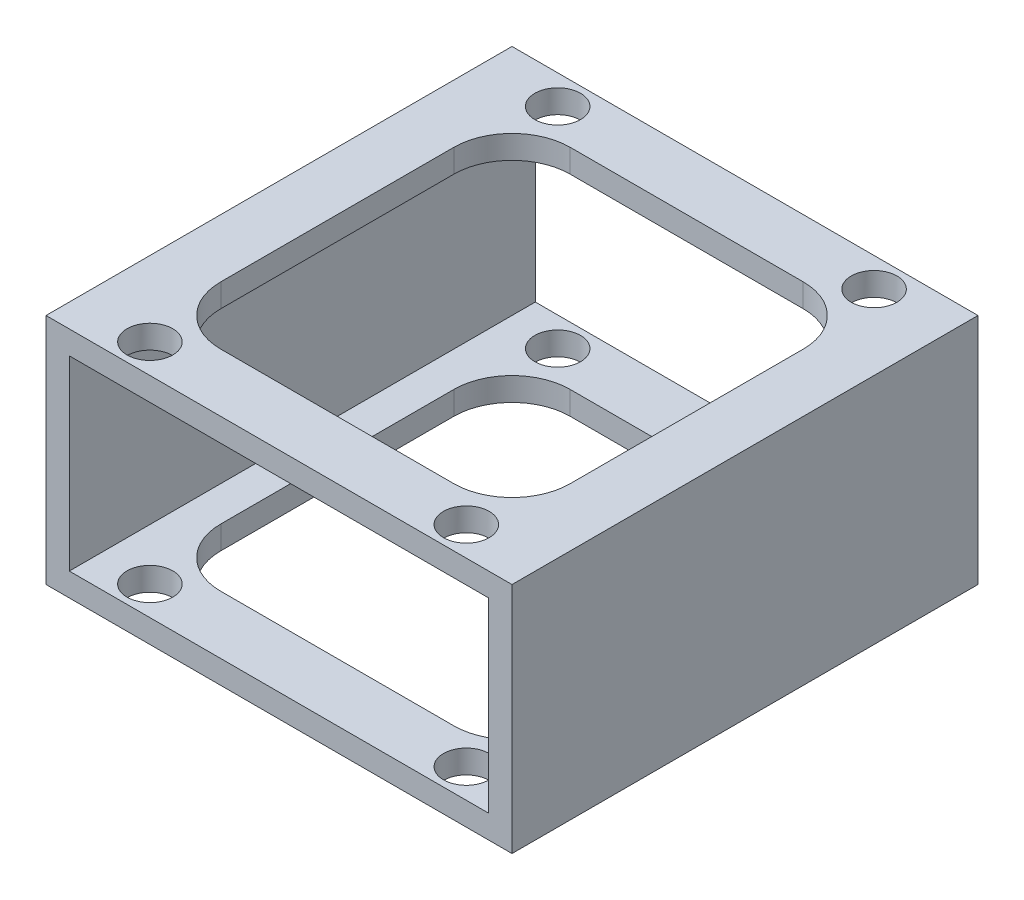
from build123d import *

# Parameters (mm, degrees)
SKETCH1_W           = 50.8
SKETCH1_H           = 25.4
SKETCH1_W_2         = 45.72
SKETCH1_H_2         = 20.32
EXTRUDE_THIN1_DEPTH = 50.8
CUT_EXTRUDE1_DEPTH  = 26.4
SKETCH3_R           = 2.4892
CUT_EXTRUDE2_DEPTH  = 26.4


with BuildPart() as part:
    # Sketch1 → Extrude-Thin1 (new body)
    with BuildSketch(Plane.XY):
        Rectangle(SKETCH1_W, SKETCH1_H)
        Rectangle(SKETCH1_W_2, SKETCH1_H_2, mode=Mode.SUBTRACT)
    extrude(amount=EXTRUDE_THIN1_DEPTH)

    # Sketch2 → Cut-Extrude1 (cut, through all)
    with BuildSketch(Plane(origin=(0, 12.7, 0), x_dir=(1, 0, 0), z_dir=(0, 1, 0))):
        with BuildLine():
            ThreePointArc((12.7, -44.45), (17.190128061, -42.590128061), (19.05, -38.1))
            Line((19.05, -38.1), (19.05, -12.7))
            ThreePointArc((19.05, -12.7), (17.190128061, -8.209871939), (12.7, -6.35))
            Line((12.7, -6.35), (-12.7, -6.35))
            ThreePointArc((-12.7, -6.35), (-17.190128061, -8.209871939), (-19.05, -12.7))
            Line((-19.05, -12.7), (-19.05, -38.1))
            ThreePointArc((-19.05, -38.1), (-17.190128061, -42.590128061), (-12.7, -44.45))
            Line((-12.7, -44.45), (12.7, -44.45))
        make_face()
    extrude(amount=-CUT_EXTRUDE1_DEPTH, mode=Mode.SUBTRACT)

    # Sketch3 → Cut-Extrude2 (cut, through all)
    with BuildSketch(Plane(origin=(0, 12.7, 0), x_dir=(1, 0, 0), z_dir=(0, 1, 0))):
        with Locations((-17.2466, -47.625)):
            Circle(SKETCH3_R)
        with Locations((17.2466, -47.625)):
            Circle(SKETCH3_R)
        with Locations((17.2466, -3.175)):
            Circle(SKETCH3_R)
        with Locations((-17.2466, -3.175)):
            Circle(SKETCH3_R)
    extrude(amount=-CUT_EXTRUDE2_DEPTH, mode=Mode.SUBTRACT)


solid = part.part
